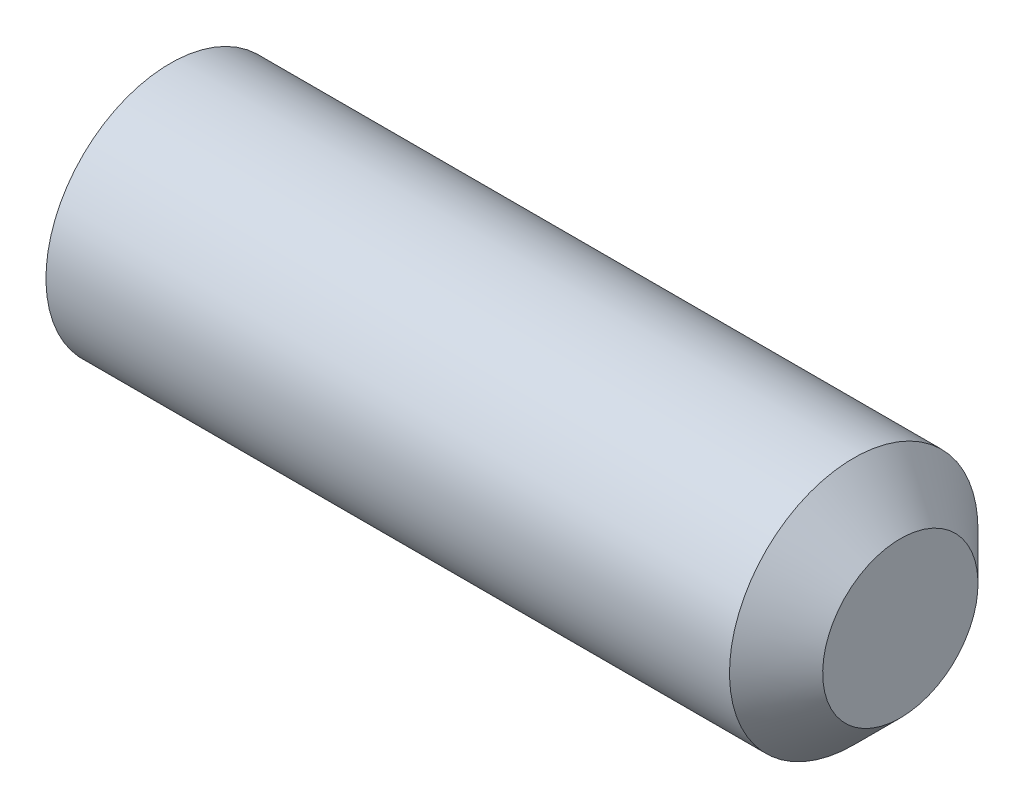
from build123d import *

# Parameters (mm, degrees)
CUT_EXTRUDE1_DEPTH = 2.5


with BuildPart() as part:
    # Sketch1 → Revolve1 (revolve)
    with BuildSketch(Plane.XY):
        Polygon((12, 0), (12, -1.25), (11.25, -2), (0.247971941, -2), (0, -1.5705), (0, -1.154700538), (0.666666667, 0), align=None)
    revolve(axis=Axis((0.666666667, 0, 0), (1, 0, 0)))

    # Sketch2 → Cut-Extrude1 (cut)
    with BuildSketch(Plane(origin=(0, 0, 0), x_dir=(0, 0, -1), z_dir=(1, 0, 0))):
        Polygon((-1.154700538, 0), (-0.577350269, -1), (0.577350269, -1), (1.154700538, 0), (0.577350269, 1), (-0.577350269, 1), align=None)
    extrude(amount=CUT_EXTRUDE1_DEPTH, mode=Mode.SUBTRACT)


solid = part.part
